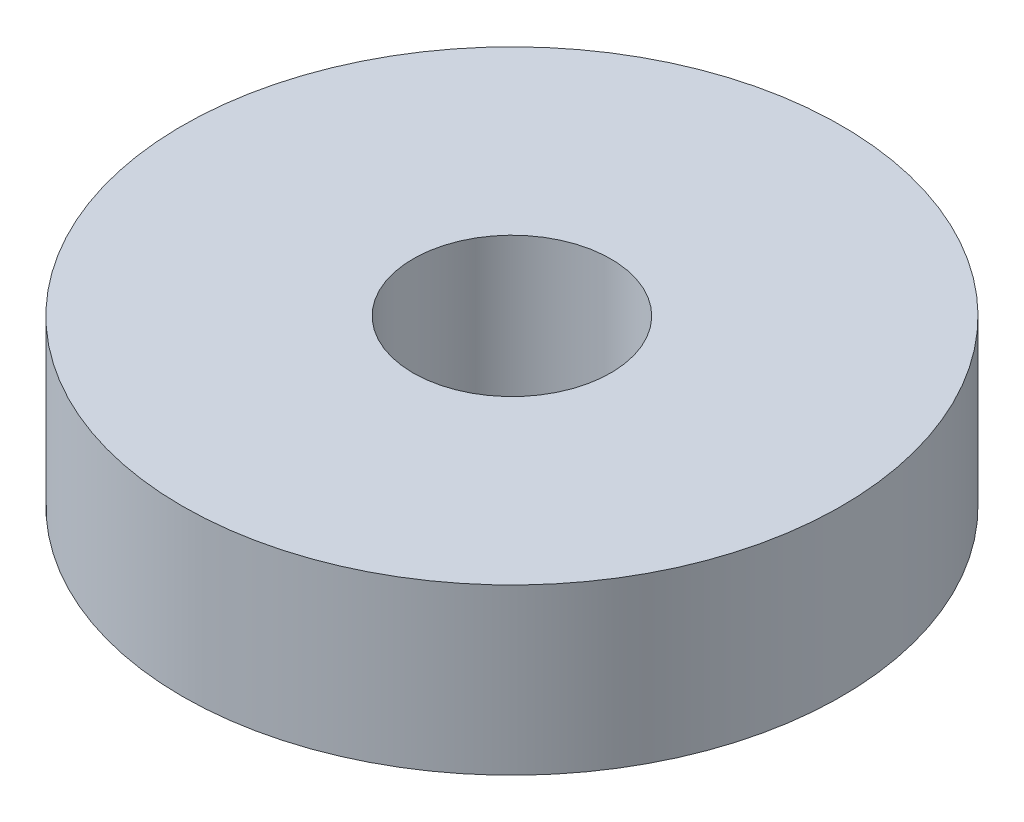
from build123d import *

# Parameters (mm, degrees)
SKETCH1_R           = 6.35
SKETCH1_R_2         = 1.905
BOSS_EXTRUDE1_DEPTH = 3.175


with BuildPart() as part:
    # Sketch1 → Boss-Extrude1 (new body)
    with BuildSketch(Plane(origin=(0, 0, 0), x_dir=(1, 0, 0), z_dir=(0, 1, 0))):
        Circle(SKETCH1_R)
        Circle(SKETCH1_R_2, mode=Mode.SUBTRACT)
    extrude(amount=BOSS_EXTRUDE1_DEPTH)


solid = part.part
